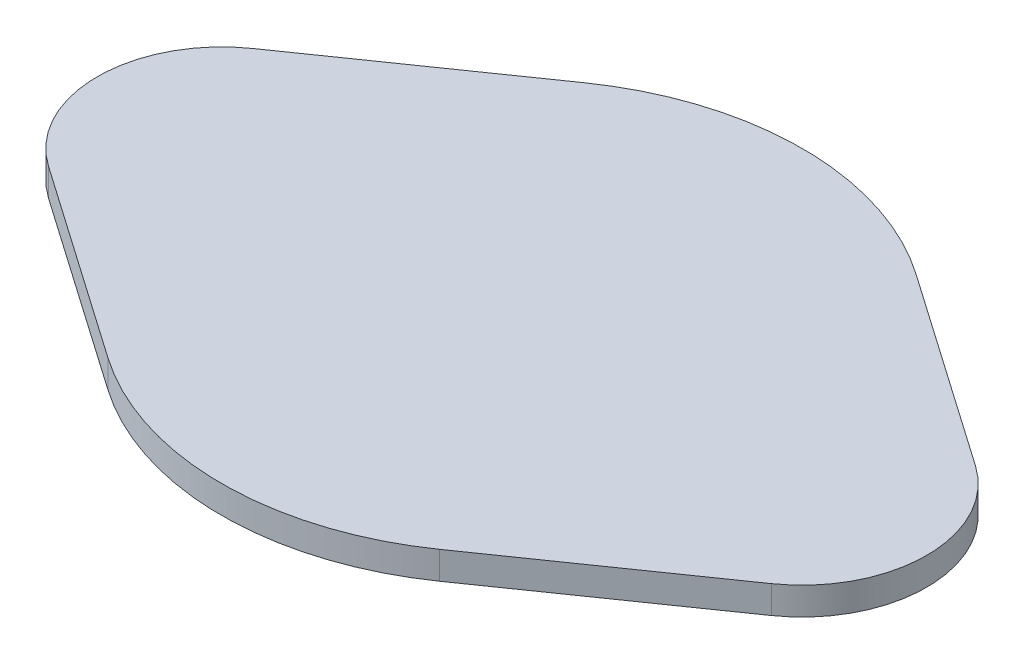
from build123d import *

# Parameters (mm, degrees)
BOSS_EXTRUDE1_DEPTH = 5


with BuildPart() as part:
    # Sketch1 → Boss-Extrude1 (new body)
    with BuildSketch(Plane(origin=(0, 0, 0), x_dir=(1, 0, 0), z_dir=(0, 1, 0))):
        with BuildLine():
            Line((-30, 43.084219849), (-65.357142857, 18.46466565))
            ThreePointArc((-65.357142857, 18.46466565), (-75, 0), (-65.357142857, -18.46466565))
            Line((-65.357142857, -18.46466565), (-30, -43.084219849))
            ThreePointArc((-30, -43.084219849), (0, -52.5), (30, -43.084219849))
            Line((30, -43.084219849), (65.357142857, -18.46466565))
            ThreePointArc((65.357142857, -18.46466565), (75, 0), (65.357142857, 18.46466565))
            Line((65.357142857, 18.46466565), (30, 43.084219849))
            ThreePointArc((30, 43.084219849), (0, 52.5), (-30, 43.084219849))
        make_face()
    extrude(amount=BOSS_EXTRUDE1_DEPTH)


solid = part.part
